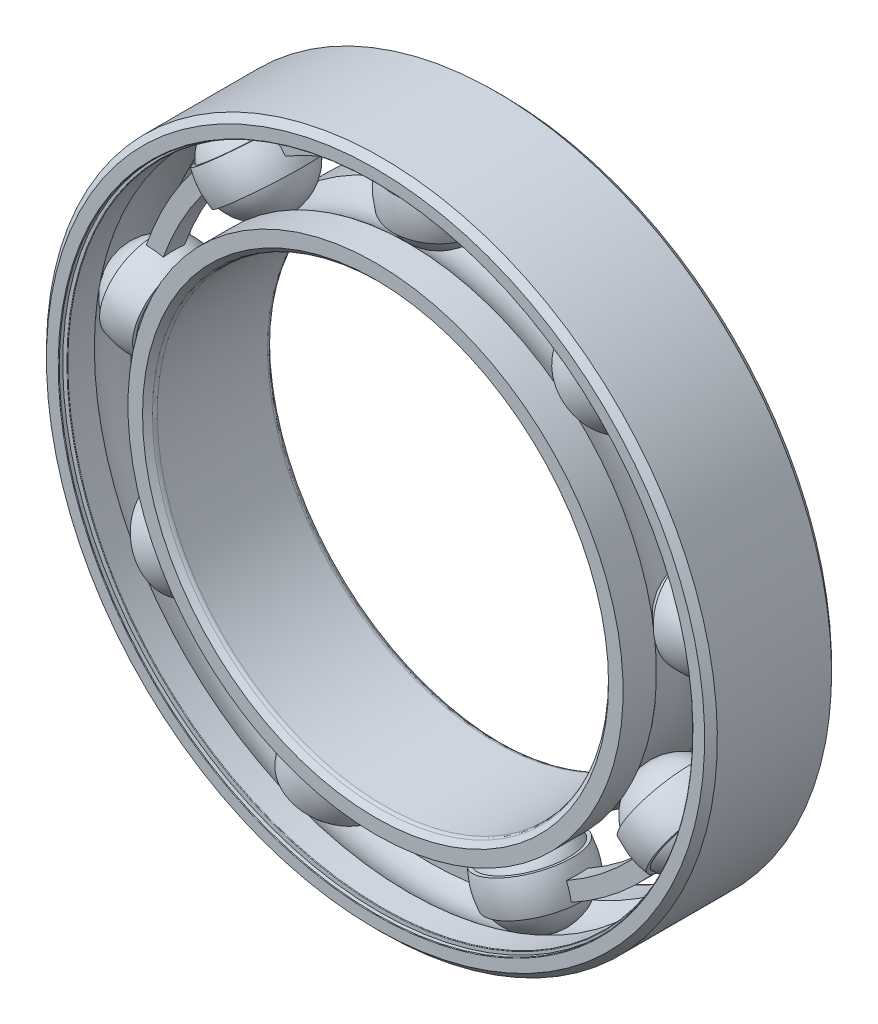
from build123d import *

# Parameters (mm, degrees)
BOSS_EXTRUDE1_DEPTH = 0.583333333
CIRPATTERN1_COUNT   = 9
CIRPATTERN2_COUNT   = 9
FILLET1_R           = 0.0315
FILLET2_R           = 0.2625


with BuildPart() as part:
    # Sketch3 → Revolve1 (revolve)
    with BuildSketch(Plane(origin=(0, 0, 0), x_dir=(0, 0, -1), z_dir=(1, 0, 0))):
        with BuildLine():
            Line((3.15, 18.5), (3.5, 18.15))
            Line((3.5, 18.15), (3.5, 17.346153846))
            Line((3.5, 17.346153846), (1.6625, 17.346153846))
            ThreePointArc((1.6625, 17.346153846), (0, 17.984389316), (-1.6625, 17.346153846))
            Line((-1.6625, 17.346153846), (-3.5, 17.346153846))
            Line((-3.5, 17.346153846), (-3.5, 18.15))
            Line((-3.5, 18.15), (-3.15, 18.5))
            Line((-3.15, 18.5), (3.15, 18.5))
        make_face()
    revolve(axis=Axis((0, 0, 3.5), (0, 0, -1)))

    # Sketch8 → Cut-Revolve1 (revolve, cut)
    with BuildSketch(Plane(origin=(0, 0, 0), x_dir=(0, 0, -1), z_dir=(1, 0, 0))):
        Polygon((-3.276, 17.346153846), (-3.15, 17.346153846), (-3.15, 17.730769231), (-3.276, 17.730769231), (-3.276, 17.472153846), (-3.5, 17.472153846), (-3.5, 17.346153846), align=None)
        Polygon((3.15, 17.346153846), (3.276, 17.346153846), (3.5, 17.346153846), (3.5, 17.472153846), (3.276, 17.472153846), (3.276, 17.730769231), (3.15, 17.730769231), align=None)
    revolve(axis=Axis((0, 0, 3.5), (0, 0, -1)), mode=Mode.SUBTRACT)

    # Fillet1
    fillet1_edges = [part.edges().sort_by_distance(p)[0] for p in [
        (0, -17.472153846, 3.5),
        (0, -17.346153846, 3.15),
        (0, -17.472153846, -3.5),
        (0, -17.346153846, -3.15),
    ]]
    fillet(fillet1_edges, radius=FILLET1_R)


with BuildPart() as body_2:
    # Sketch4 → Revolve2 (revolve)
    with BuildSketch(Plane(origin=(0, 0, 0), x_dir=(0, 0, -1), z_dir=(1, 0, 0))):
        with BuildLine():
            Line((-3.15, 12.5), (-3.5, 12.85))
            Line((-3.5, 12.85), (-3.5, 13.653846154))
            Line((-3.5, 13.653846154), (-1.6625, 13.653846154))
            ThreePointArc((-1.6625, 13.653846154), (0, 13.015610684), (1.6625, 13.653846154))
            Line((1.6625, 13.653846154), (3.5, 13.653846154))
            Line((3.5, 13.653846154), (3.5, 12.85))
            Line((3.5, 12.85), (3.15, 12.5))
            Line((3.15, 12.5), (-3.15, 12.5))
        make_face()
    revolve(axis=Axis((0, 0, 3.5), (0, 0, -1)))

    # Fillet2
    fillet2_edges = [body_2.edges().sort_by_distance(p)[0] for p in [
        (0, -12.5, 3.15),
        (0, -12.5, -3.15),
    ]]
    fillet(fillet2_edges, radius=FILLET2_R)


with BuildPart() as body_3:
    # Sketch5 → Revolve3 (revolve)
    with BuildSketch(Plane(origin=(0, 0, 0), x_dir=(0, 0, -1), z_dir=(1, 0, 0))):
        with BuildLine():
            Line((-2.484389316, 15.5), (2.484389316, 15.5))
            ThreePointArc((2.484389316, 15.5), (0, 17.984389316), (-2.484389316, 15.5))
        make_face()
    revolve(axis=Axis((0, 15.5, 2.484389316), (0, 0, -1)))


with BuildPart() as body_4:
    # Sketch6 → Revolve4 (revolve)
    with BuildSketch(Plane(origin=(0, 0, 0), x_dir=(0, 0, -1), z_dir=(1, 0, 0))):
        with BuildLine():
            Line((-2.306538373, 16.423076923), (-2.505448644, 16.423076923))
            ThreePointArc((-2.505448644, 16.423076923), (-2.60490378, 15.5), (-2.505448644, 14.576923077))
            Line((-2.505448644, 14.576923077), (-2.306538373, 14.576923077))
            ThreePointArc((-2.306538373, 14.576923077), (-2.484389316, 15.5), (-2.306538373, 16.423076923))
        make_face()
    revolve4 = revolve(axis=Axis((0, 18.5, 0), (0, -1, 0)))

    # Sketch7 → Boss-Extrude1 (add, symmetric)
    with BuildSketch(Plane.XY):
        with BuildLine():
            Line((9.642968818, 12.135203022), (10.217239914, 12.857895013))
            ThreePointArc((10.217239914, 12.857895013), (5.410695739, 15.506186741), (0, 16.423076923))
            Line((0, 16.423076923), (0, 15.5))
            ThreePointArc((0, 15.5), (5.106581692, 14.634644629), (9.642968818, 12.135203022))
        make_face()
    boss_extrude1 = extrude(amount=BOSS_EXTRUDE1_DEPTH, both=True)

    # CirPattern2: Revolve4, Boss-Extrude1 ×9 about axis
    cirpattern2_axis = Axis((0, 0, 0), (0, 0, 1))
    for i in range(1, CIRPATTERN2_COUNT):
        add(revolve4.rotate(cirpattern2_axis, i * 360 / CIRPATTERN2_COUNT))
        add(boss_extrude1.rotate(cirpattern2_axis, i * 360 / CIRPATTERN2_COUNT))


with BuildPart() as cirpattern1_1:
    # CirPattern1: pattern copy
    add(body_3.part.rotate(Axis((0, 0, 0), (0, 0, 1)), 1 * 360 / CIRPATTERN1_COUNT))


with BuildPart() as cirpattern1_2:
    # CirPattern1: pattern copy
    add(body_3.part.rotate(Axis((0, 0, 0), (0, 0, 1)), 2 * 360 / CIRPATTERN1_COUNT))


with BuildPart() as cirpattern1_3:
    # CirPattern1: pattern copy
    add(body_3.part.rotate(Axis((0, 0, 0), (0, 0, 1)), 3 * 360 / CIRPATTERN1_COUNT))


with BuildPart() as cirpattern1_4:
    # CirPattern1: pattern copy
    add(body_3.part.rotate(Axis((0, 0, 0), (0, 0, 1)), 4 * 360 / CIRPATTERN1_COUNT))


with BuildPart() as cirpattern1_5:
    # CirPattern1: pattern copy
    add(body_3.part.rotate(Axis((0, 0, 0), (0, 0, 1)), 5 * 360 / CIRPATTERN1_COUNT))


with BuildPart() as cirpattern1_6:
    # CirPattern1: pattern copy
    add(body_3.part.rotate(Axis((0, 0, 0), (0, 0, 1)), 6 * 360 / CIRPATTERN1_COUNT))


with BuildPart() as cirpattern1_7:
    # CirPattern1: pattern copy
    add(body_3.part.rotate(Axis((0, 0, 0), (0, 0, 1)), 7 * 360 / CIRPATTERN1_COUNT))


with BuildPart() as cirpattern1_8:
    # CirPattern1: pattern copy
    add(body_3.part.rotate(Axis((0, 0, 0), (0, 0, 1)), 8 * 360 / CIRPATTERN1_COUNT))


solid = Compound([part.part, body_2.part, body_3.part, body_4.part, cirpattern1_1.part, cirpattern1_2.part, cirpattern1_3.part, cirpattern1_4.part, cirpattern1_5.part, cirpattern1_6.part, cirpattern1_7.part, cirpattern1_8.part])
